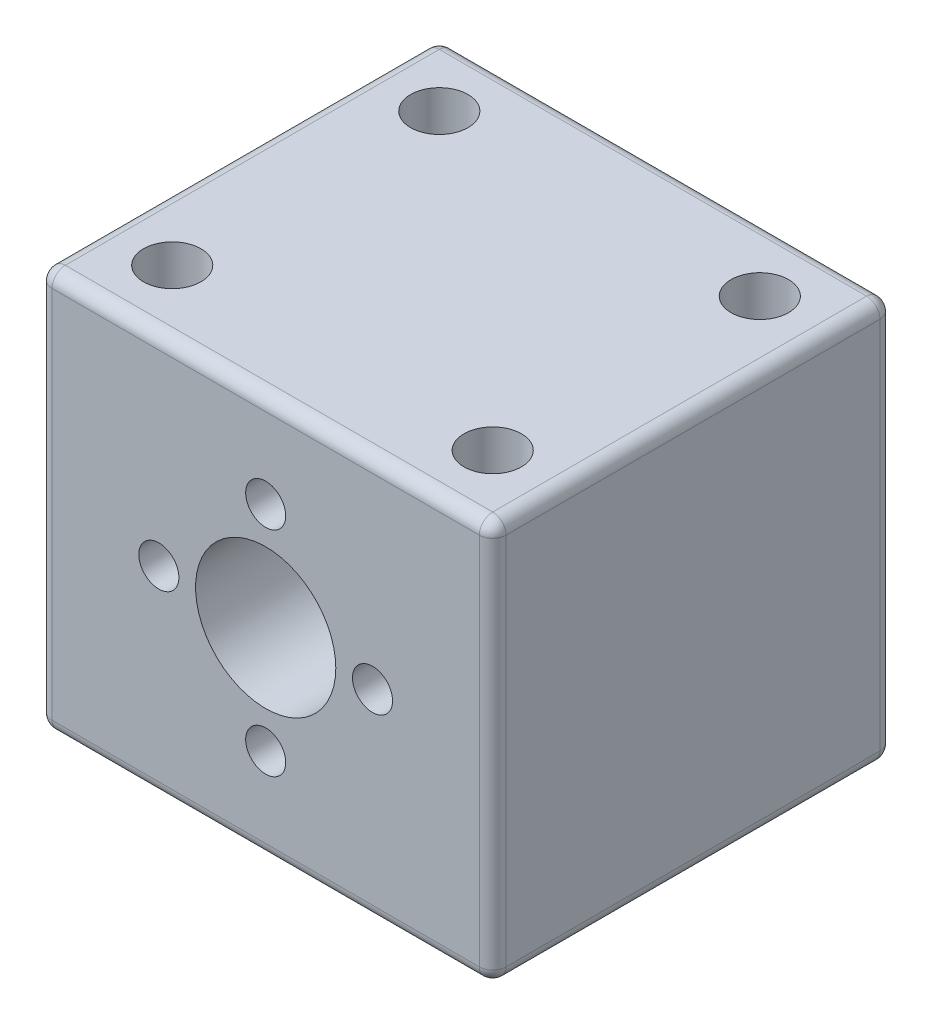
from build123d import *

# Parameters (mm, degrees)
SKETCH1_W           = 34
SKETCH1_H           = 30
BOSS_EXTRUDE1_DEPTH = 30
SKETCH2_R           = 5.25
CUT_EXTRUDE1_DEPTH  = 30
SKETCH3_R           = 1.5
CUT_EXTRUDE2_DEPTH  = 15
FILLET1_R           = 1
SKETCH4_R           = 2.15
CUT_EXTRUDE3_DEPTH  = 20


with BuildPart() as part:
    # Sketch1 → Boss-Extrude1 (new body)
    with BuildSketch(Plane.XY):
        with Locations((17, -15)):
            Rectangle(SKETCH1_W, SKETCH1_H)
    extrude(amount=BOSS_EXTRUDE1_DEPTH)

    # Sketch2 → Cut-Extrude1 (cut)
    with BuildSketch(Plane.XY.offset(30)):
        with Locations((17, -15)):
            Circle(SKETCH2_R)
    extrude(amount=-CUT_EXTRUDE1_DEPTH, mode=Mode.SUBTRACT)

    # Sketch3 → Cut-Extrude2 (cut)
    with BuildSketch(Plane.XY.offset(30)):
        with Locations((25, -15)):
            Circle(SKETCH3_R)
        with Locations((17, -7)):
            Circle(SKETCH3_R)
        with Locations((9, -15)):
            Circle(SKETCH3_R)
        with Locations((17, -23)):
            Circle(SKETCH3_R)
    extrude(amount=-CUT_EXTRUDE2_DEPTH, mode=Mode.SUBTRACT)

    # Fillet1
    fillet1_edges = [part.edges().sort_by_distance(p)[0] for p in [
        (34, -15, 30),
        (17, 0, 30),
        (0, -15, 30),
        (17, 0, 0),
        (34, -15, 0),
        (17, -30, 0),
        (0, -15, 0),
        (0, 0, 15),
        (34, 0, 15),
        (34, -30, 15),
        (0, -30, 15),
        (17, -30, 30),
    ]]
    fillet(fillet1_edges, radius=FILLET1_R)

    # Sketch4 → Cut-Extrude3 (cut)
    with BuildSketch(Plane(origin=(0, 0, 0), x_dir=(1, 0, 0), z_dir=(0, 1, 0))):
        with Locations((5, -5)):
            Circle(SKETCH4_R)
        with Locations((29, -5)):
            Circle(SKETCH4_R)
        with Locations((29, -25)):
            Circle(SKETCH4_R)
        with Locations((5, -25)):
            Circle(SKETCH4_R)
    extrude(amount=-CUT_EXTRUDE3_DEPTH, mode=Mode.SUBTRACT)


solid = part.part
